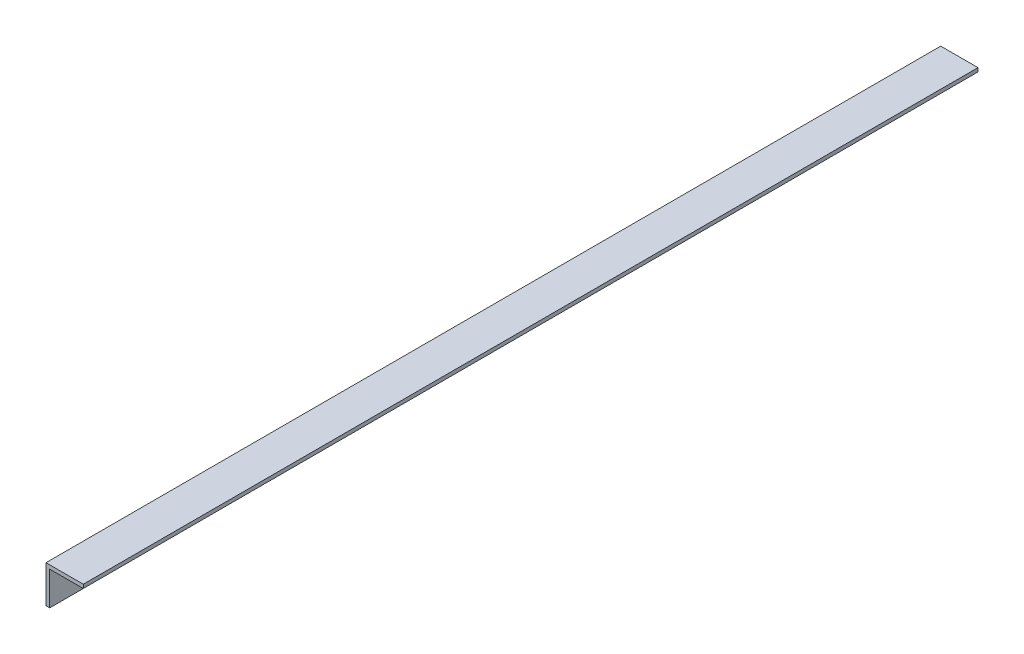
from build123d import *

# Parameters (mm, degrees)
EXTRUDE_1_DEPTH = 1200


with BuildPart() as part:
    # Эскиз1 → Вытянуть-Тонкостенный1 (new body)
    with BuildSketch(Plane.XY):
        Polygon((50, 0), (0, 0), (0, -50), (5, -50), (5, -5), (50, -5), align=None)
    extrude(amount=-EXTRUDE_1_DEPTH)


solid = part.part
